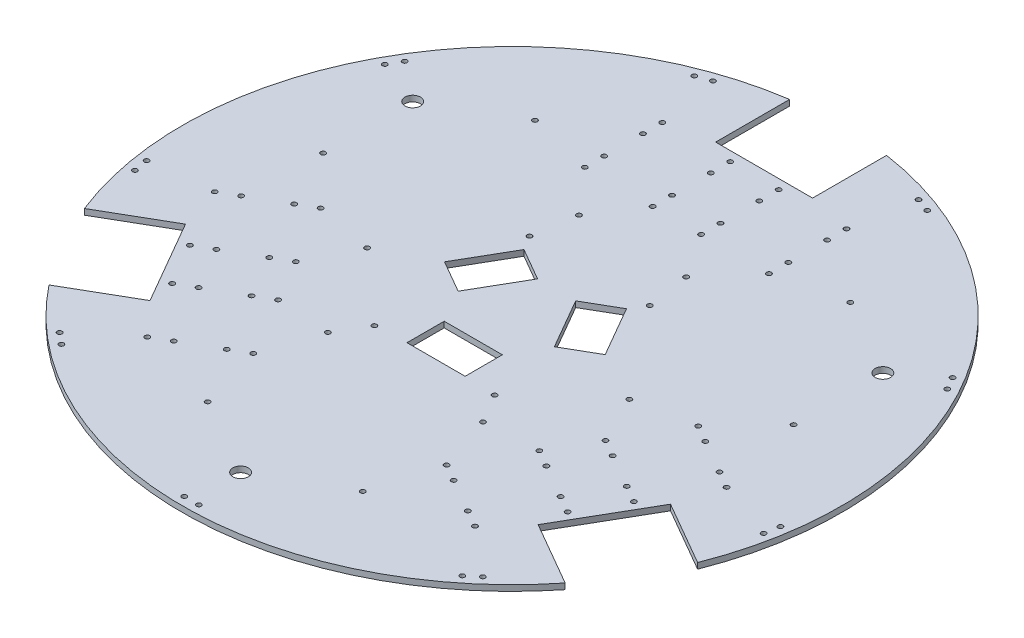
from build123d import *

# Parameters (mm, degrees)
SKETCH_1_R              = 170
EXTRUDE_1_DEPTH         = 3
SKETCH_2_W              = 50
SKETCH_2_H              = 56.899134832
CUT_EXTRUDE_1_DEPTH     = 3
SKETCH_4_R              = 4
CUT_EXTRUDE_3_DEPTH     = 3
HOLE_WIZARD_M3_2_D      = 2.5
HOLE_WIZARD_M3_2_DEPTH  = 3
SKETCH_15_W             = 30
SKETCH_15_H             = 19.192042138
CUT_EXTRUDE_5_DEPTH     = 10
HOLE_WIZARD_M3_12_D     = 2.5
HOLE_WIZARD_M3_12_DEPTH = 3


with BuildPart() as part:
    # Sketch 1 → Extrude 1 (new body)
    with BuildSketch(Plane(origin=(0, 0, 0), x_dir=(1, 0, 0), z_dir=(0, 1, 0))):
        with Locations(Location((0, 0, 0), (0, 0, 270))):  # turned: the seam where the file's is
            Circle(SKETCH_1_R)
    extrude(amount=EXTRUDE_1_DEPTH)

    # Sketch 2 → Cut-Extrude 1 (cut)
    with BuildSketch(Plane(origin=(0, 3, 0), x_dir=(1, 0, 0), z_dir=(0, 1, 0))):
        Polygon((100.083302492, -86.650635095), (125.083302492, -43.349364905), (166.35664483, -67.178540215), (141.35664483, -110.479810404), align=None)
        with Locations((0, 158.449567416)):
            Rectangle(SKETCH_2_W, SKETCH_2_H)
        Polygon((-125.083302492, -43.349364905), (-100.083302492, -86.650635095), (-146.483158101, -113.439604221), (-171.483158101, -70.138334032), align=None)
    extrude(amount=-CUT_EXTRUDE_1_DEPTH, mode=Mode.SUBTRACT)

    # Sketch 4 → Cut-Extrude 3 (cut)
    with BuildSketch(Plane(origin=(0, 3, 0), x_dir=(1, 0, 0), z_dir=(0, 1, 0))):
        with Locations(Location((0, -140, 0), (0, 0, 270))):  # turned: the seam where the file's is
            Circle(SKETCH_4_R)
        with Locations(Location((-121.24355653, 70, 0), (0, 0, 270))):  # turned: the seam where the file's is
            Circle(SKETCH_4_R)
        with Locations(Location((121.24355653, 70, 0), (0, 0, 270))):  # turned: the seam where the file's is
            Circle(SKETCH_4_R)
    extrude(amount=-CUT_EXTRUDE_3_DEPTH, mode=Mode.SUBTRACT)

    # Hole Wizard M3 _2
    with Locations(Plane(origin=(-53.015568193, 3, -156.623342989), x_dir=(0, 0, 1), z_dir=(0, 1, 0))):
        with Locations((0, 0), (2.565151075, -7.047694655), (70.720651784, -88.272257481), (77.215842312, -92.022257481), (181.636127485, -110.43437109), (189.022185633, -109.132009758), (280.847843334, -56.116441565), (285.668750407, -50.371108242), (321.93353487, 49.265568193), (321.93353487, 56.765568193), (285.668750407, 156.402244628), (280.847843334, 162.147577951), (189.022185633, 215.163146144), (181.636127485, 216.465507476), (77.215842312, 198.053393867), (70.720651784, 194.303393867), (0, 106.031136386), (2.565151075, 113.078831041), (116.623342989, 84.015568193), (116.623342989, 22.015568193), (196.623342989, 22.015568193), (196.623342989, 84.015568193)):
            Hole(HOLE_WIZARD_M3_2_D / 2, depth=HOLE_WIZARD_M3_2_DEPTH)

    # Sketch 15 → Cut-Extrude 5 (cut)
    with BuildSketch(Plane(origin=(0, 3, 0), x_dir=(1, 0, 0), z_dir=(0, 1, 0))):
        with Locations((0, -29.596021069)):
            Rectangle(SKETCH_15_W, SKETCH_15_H)
        Polygon((-9.820508076, 22.990381057), (-24.820508076, -2.990381057), (-41.441304118, 6.605640012), (-26.441304118, 32.586402126), align=None)
        Polygon((24.820508076, -2.990381057), (9.820508076, 22.990381057), (26.441304118, 32.586402126), (41.441304118, 6.605640012), align=None)
    extrude(amount=-CUT_EXTRUDE_5_DEPTH, mode=Mode.SUBTRACT)

    # Hole Wizard M3 _12
    with Locations(Plane(origin=(-47.5, 3, -125), x_dir=(0, 0, 1), z_dir=(0, 1, 0))):
        with Locations((0, 0), (10, 0), (30, 0), (40, 0), (40, 35), (30, 35), (10, 35), (0, 35), (0, 60), (10, 60), (30, 60), (40, 60), (40, 95), (30, 95), (10, 95), (0, 95), (31.858226152, 128.826284612), (62.858226152, 75.132709578), (132.140258455, 115.132709578), (101.140258455, 168.826284612), (126.36379332, 144.862159322), (131.36379332, 153.52241336), (141.36379332, 170.842921435), (146.36379332, 179.503175473), (176.674682453, 162.003175473), (171.674682453, 153.342921435), (161.674682453, 136.02241336), (156.674682453, 127.362159322), (178.325317547, 114.862159322), (183.325317547, 123.52241336), (193.325317547, 140.842921435), (198.325317547, 149.503175473), (228.63620668, 132.003175473), (223.63620668, 123.342921435), (213.63620668, 106.02241336), (208.63620668, 97.362159322), (180.001515394, 87.5), (242.001515394, 87.5), (242.001515394, 7.5), (180.001515394, 7.5), (228.63620668, -37.003175473), (223.63620668, -28.342921435), (213.63620668, -11.022413359), (208.63620668, -2.362159322), (178.325317547, -19.862159322), (183.325317547, -28.522413359), (193.325317547, -45.842921435), (198.325317547, -54.503175473), (176.674682453, -67.003175473), (171.674682453, -58.342921435), (161.674682453, -41.022413359), (156.674682453, -32.362159322), (126.36379332, -49.862159322), (131.36379332, -58.522413359), (141.36379332, -75.842921435), (146.36379332, -84.503175473), (31.858226152, -33.826284612), (101.140258455, -73.826284612), (132.140258455, -20.132709578), (62.858226152, 19.867290422)):
            Hole(HOLE_WIZARD_M3_12_D / 2, depth=HOLE_WIZARD_M3_12_DEPTH)


solid = part.part
